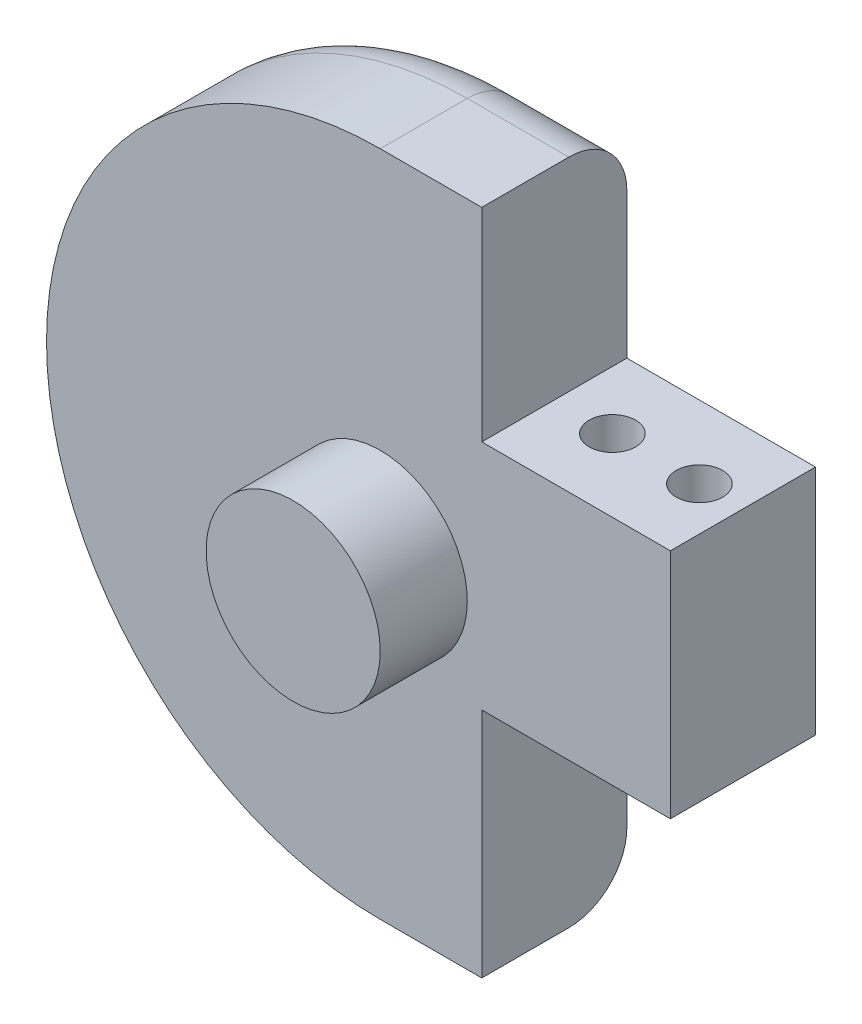
from build123d import *

# Parameters (mm, degrees)
BOSS_EXTRUDE1_DEPTH = 5
CUT_EXTRUDE1_START  = 11
SKETCH2_R           = 0.8
CUT_EXTRUDE1_DEPTH  = 23
BOSS_EXTRUDE2_START = 5
SKETCH4_R           = 3
BOSS_EXTRUDE2_DEPTH = 3
FILLET1_R           = 2


with BuildPart() as part:
    # Sketch1 → Boss-Extrude1 (new body)
    with BuildSketch(Plane.XY):
        with BuildLine():
            Line((3.5, 12), (3.5, 5))
            Line((3.5, 5), (10, 5))
            Line((10, 5), (10, -3))
            Line((10, -3), (3.5, -3))
            Line((3.5, -3), (3.5, -11))
            Line((3.5, -11), (0, -11))
            ThreePointArc((0, -11), (-11.5, 0.5), (0, 12))
            Line((0, 12), (3.5, 12))
        make_face()
    extrude(amount=BOSS_EXTRUDE1_DEPTH)

    # Sketch2 → Cut-Extrude1 (cut, through all)
    with BuildSketch(Plane(origin=(0, 0, 0), x_dir=(1, 0, 0), z_dir=(0, 1, 0)).offset(CUT_EXTRUDE1_START)):
        with Locations((8.5, -2.5)):
            Circle(SKETCH2_R)
        with Locations((5.5, -2.5)):
            Circle(SKETCH2_R)
    extrude(amount=-CUT_EXTRUDE1_DEPTH, mode=Mode.SUBTRACT)

    # Sketch4 → Boss-Extrude2 (add)
    with BuildSketch(Plane.XY.offset(BOSS_EXTRUDE2_START)):
        Circle(SKETCH4_R)
    extrude(amount=BOSS_EXTRUDE2_DEPTH)

    # Fillet1
    fillet1_edges = [part.edges().sort_by_distance(p)[0] for p in [
        (1.75, -11, 0),
        (-11.5, 0.5, 0),
        (1.75, 12, 0),
    ]]
    fillet(fillet1_edges, radius=FILLET1_R)


solid = part.part
